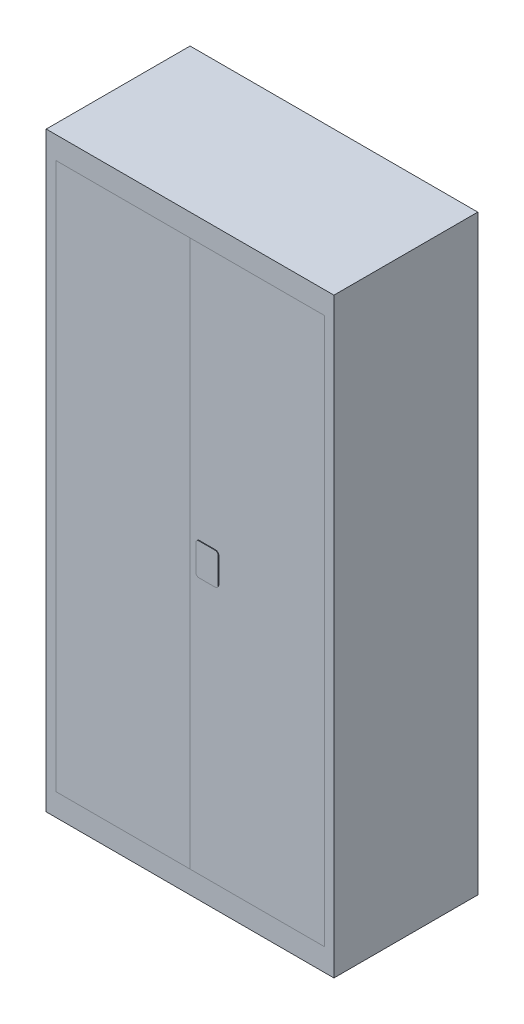
from build123d import *

# Parameters (mm, degrees)
SKETCH1_W           = 900
SKETCH1_H           = 1850
BOSS_EXTRUDE1_DEPTH = 450
SKETCH2_W           = 840
SKETCH2_H           = 1710
CUT_EXTRUDE1_DEPTH  = 20
BOSS_EXTRUDE2_START = -20
SKETCH2_3_W         = 420
SKETCH2_3_H         = 1710
BOSS_EXTRUDE2_DEPTH = 20
BOSS_EXTRUDE3_START = -20
SKETCH2_4_W         = 420
SKETCH2_4_H         = 1710
BOSS_EXTRUDE3_DEPTH = 20
BOSS_EXTRUDE4_DEPTH = 2


with BuildPart() as part:
    # Sketch1 → Boss-Extrude1 (new body)
    with BuildSketch(Plane.XY):
        with Locations((450, 925)):
            Rectangle(SKETCH1_W, SKETCH1_H)
    extrude(amount=-BOSS_EXTRUDE1_DEPTH)

    # Sketch2 → Cut-Extrude1 (cut)
    with BuildSketch(Plane.XY):
        with Locations((450, 925)):
            Rectangle(SKETCH2_W, SKETCH2_H)
    extrude(amount=-CUT_EXTRUDE1_DEPTH, mode=Mode.SUBTRACT)


with BuildPart() as body_2:
    # Sketch2_3 → Boss-Extrude2 (new body)
    with BuildSketch(Plane.XY.offset(BOSS_EXTRUDE2_START)):
        with Locations((240, 925)):
            Rectangle(SKETCH2_3_W, SKETCH2_3_H)
    extrude(amount=BOSS_EXTRUDE2_DEPTH)


with BuildPart() as body_3:
    # Sketch2_4 → Boss-Extrude3 (new body)
    with BuildSketch(Plane.XY.offset(BOSS_EXTRUDE3_START)):
        with Locations((660, 925)):
            Rectangle(SKETCH2_4_W, SKETCH2_4_H)
    extrude(amount=BOSS_EXTRUDE3_DEPTH)

    # Sketch3 → Boss-Extrude4 (add)
    with BuildSketch(Plane.XY):
        with BuildLine():
            Line((480, 975), (530, 975))
            ThreePointArc((530, 975), (537.071067812, 972.071067812), (540, 965))
            Line((540, 965), (540, 885))
            ThreePointArc((540, 885), (537.071067812, 877.928932188), (530, 875))
            Line((530, 875), (480, 875))
            ThreePointArc((480, 875), (472.928932188, 877.928932188), (470, 885))
            Line((470, 885), (470, 965))
            ThreePointArc((470, 965), (472.928932188, 972.071067812), (480, 975))
        make_face()
    extrude(amount=BOSS_EXTRUDE4_DEPTH)


solid = Compound([part.part, body_2.part, body_3.part])
